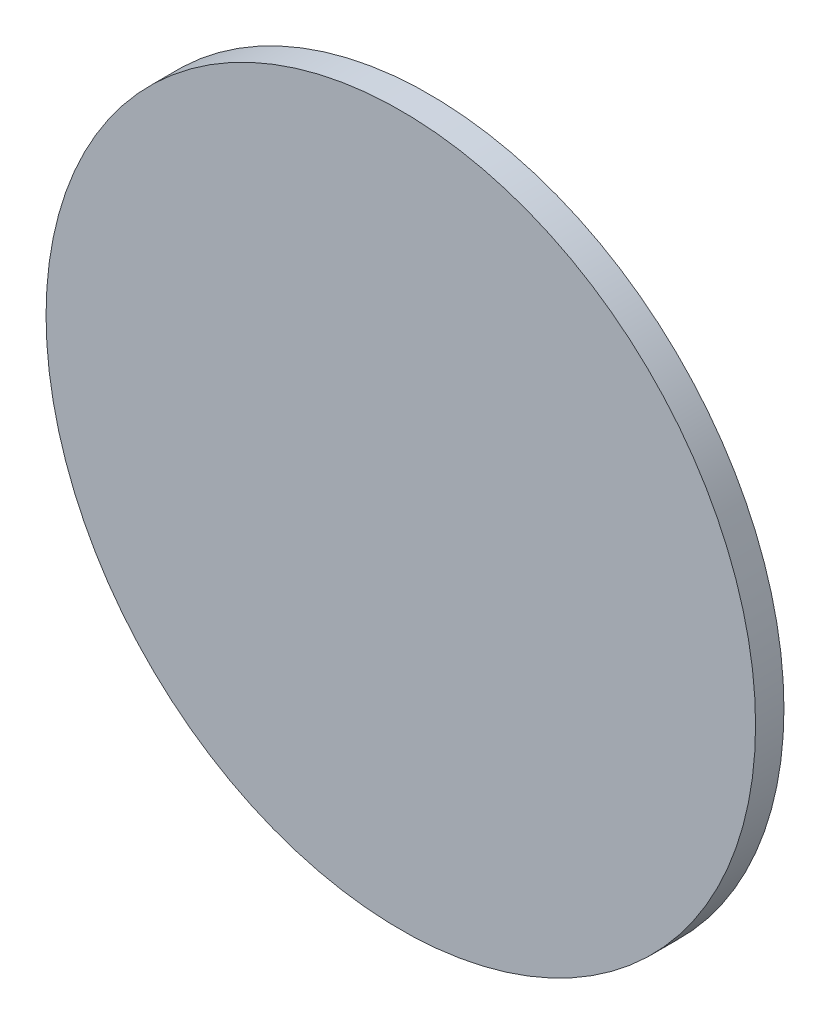
from build123d import *

# Parameters (mm, degrees)
SKETCH_1_R      = 12.5
EXTRUDE_1_DEPTH = 1


with BuildPart() as part:
    # 草图1 → 凸台-拉伸1 (new body)
    with BuildSketch(Plane.XY):
        Circle(SKETCH_1_R)
    extrude(amount=EXTRUDE_1_DEPTH)


solid = part.part
